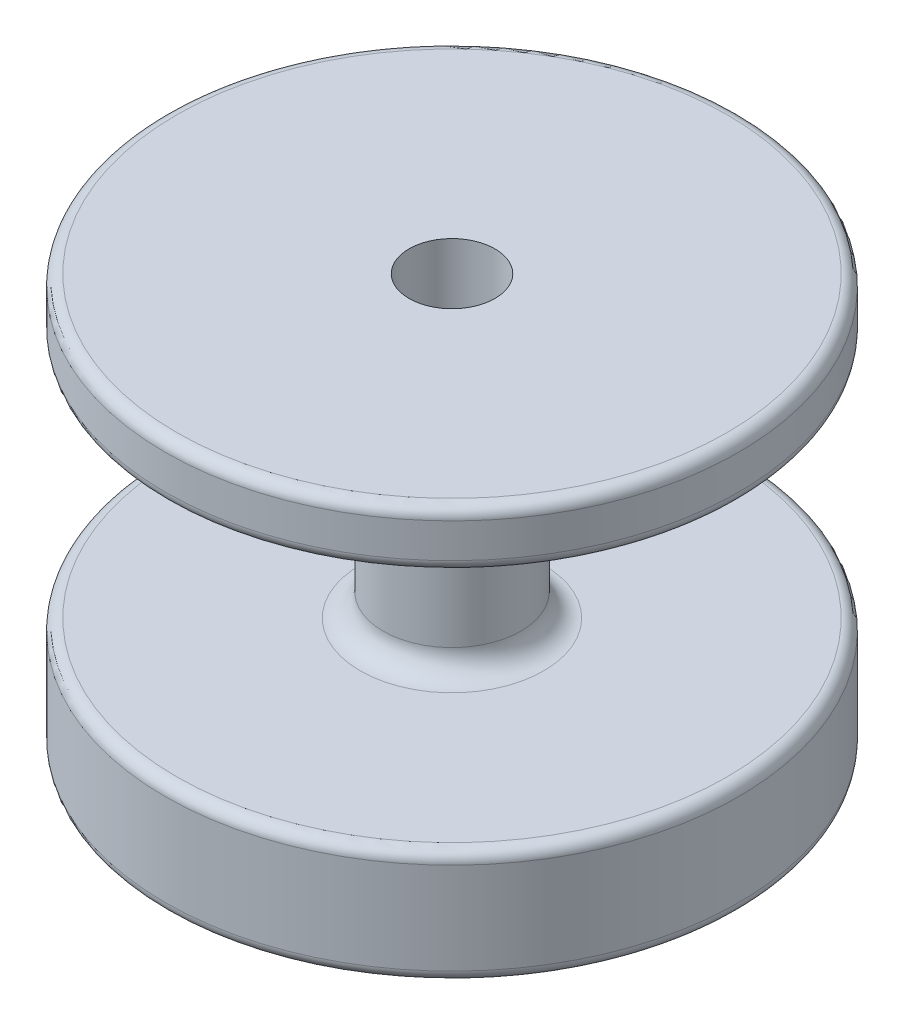
from build123d import *

# Parameters (mm, degrees)
SKETCH_1_R               = 25
EXTRUDE_1_DEPTH          = 36
CUT_EXTRUDE_START        = 10
SKETCH_2_R               = 25
SKETCH_2_R_2             = 6
CUT_EXTRUDE_1_DEPTH      = 21
SKETCH_4_R               = 2
CUT_EXTRUDE_3_DEPTH      = 47
CUT_EXTRUDE_3_DEPTH_BACK = 47
SKETCH_3_R               = 3.75
CUT_EXTRUDE_7_DEPTH      = 17
FILLET_1_R               = 1
FILLET_2_R               = 2


with BuildPart() as part:
    # 草图1 → 凸台-拉伸1 (new body)
    with BuildSketch(Plane(origin=(0, 0, 0), x_dir=(1, 0, 0), z_dir=(0, 1, 0))):
        Circle(SKETCH_1_R)
    extrude(amount=EXTRUDE_1_DEPTH)

    # 草图2 → 切除-拉伸1 (cut)
    with BuildSketch(Plane(origin=(0, 0, 0), x_dir=(1, 0, 0), z_dir=(0, 1, 0)).offset(CUT_EXTRUDE_START)):
        Circle(SKETCH_2_R)
        Circle(SKETCH_2_R_2, mode=Mode.SUBTRACT)
    extrude(amount=CUT_EXTRUDE_1_DEPTH, mode=Mode.SUBTRACT)

    # 草图4 → 切除-拉伸3 (cut, two sides)
    with BuildSketch(Plane(origin=(0, 0, 0), x_dir=(1, 0, 0), z_dir=(0, 1, 0))) as cut_extrude_3_sk:
        Circle(SKETCH_4_R)
    extrude(amount=CUT_EXTRUDE_3_DEPTH, mode=Mode.SUBTRACT)
    extrude(cut_extrude_3_sk.sketch, amount=-CUT_EXTRUDE_3_DEPTH_BACK, mode=Mode.SUBTRACT)

    # 草图3 → 切除-拉伸7 (cut)
    with BuildSketch(Plane(origin=(0, 36, 0), x_dir=(1, 0, 0), z_dir=(0, 1, 0))):
        Circle(SKETCH_3_R)
    extrude(amount=-CUT_EXTRUDE_7_DEPTH, mode=Mode.SUBTRACT)

    # 圆角1
    fillet_1_edges = [part.edges().sort_by_distance(p)[0] for p in [
        (-25, 0, 0),
        (-25, 36, 0),
        (-25, 10, 0),
        (-25, 31, 0),
    ]]
    fillet(fillet_1_edges, radius=FILLET_1_R)

    # 圆角2
    fillet_2_edges = [part.edges().sort_by_distance(p)[0] for p in [
        (-6, 31, 0),
        (-6, 10, 0),
    ]]
    fillet(fillet_2_edges, radius=FILLET_2_R)


solid = part.part
